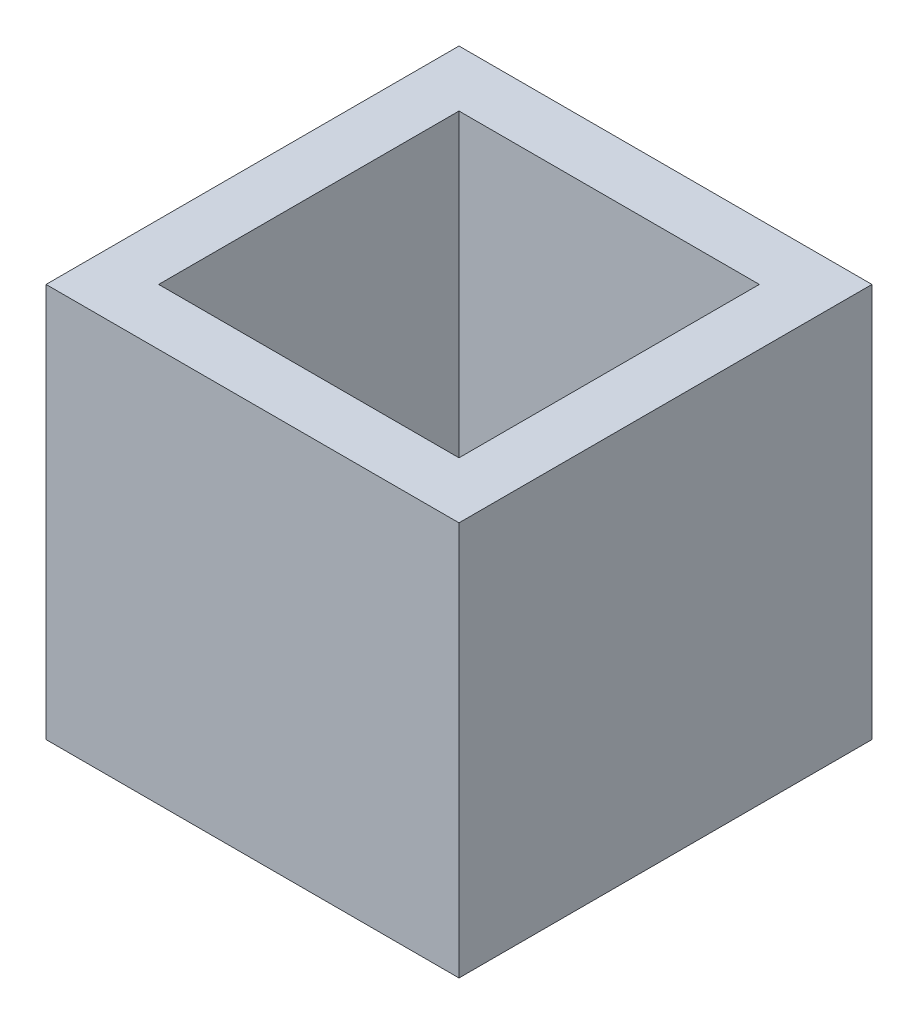
from build123d import *

# Parameters (mm, degrees)
SKETCH1_W           = 12
SKETCH1_H           = 12
BOSS_EXTRUDE1_DEPTH = 11
SHELL1_T            = -2
SKETCH3_R           = 0.625
CUT_EXTRUDE1_DEPTH  = 10
SKETCH4_W           = 12
SKETCH4_H           = 12
SKETCH4_W_2         = 11
SKETCH4_H_2         = 11
CUT_EXTRUDE2_DEPTH  = 12
SKETCH5_W           = 11
SKETCH5_H           = 11
CUT_EXTRUDE3_DEPTH  = 0.5


with BuildPart() as part:
    # Sketch1 → Boss-Extrude1 (new body)
    with BuildSketch(Plane(origin=(0, 0, 0), x_dir=(1, 0, 0), z_dir=(0, 1, 0))):
        with Locations((6, 6)):
            Rectangle(SKETCH1_W, SKETCH1_H)
    extrude(amount=BOSS_EXTRUDE1_DEPTH)

    # Shell1
    shell1_openings = [part.faces().sort_by_distance(p)[0] for p in [
        (6, 11, -6),
    ]]
    offset(amount=SHELL1_T, openings=shell1_openings, kind=Kind.INTERSECTION)

    # Sketch3 → Cut-Extrude1 (cut)
    with BuildSketch(Plane.XZ):
        with Locations((6, -4.73)):
            Circle(SKETCH3_R)
        with Locations((6, -7.27)):
            Circle(SKETCH3_R)
    extrude(amount=-CUT_EXTRUDE1_DEPTH, mode=Mode.SUBTRACT)

    # Sketch4 → Cut-Extrude2 (cut, through all)
    with BuildSketch(Plane(origin=(0, 11, 0), x_dir=(1, 0, 0), z_dir=(0, 1, 0))):
        with Locations((6, 6)):
            Rectangle(SKETCH4_W, SKETCH4_H)
        with Locations((6, 6)):
            Rectangle(SKETCH4_W_2, SKETCH4_H_2, mode=Mode.SUBTRACT)
    extrude(amount=-CUT_EXTRUDE2_DEPTH, mode=Mode.SUBTRACT)

    # Sketch5 → Cut-Extrude3 (cut)
    with BuildSketch(Plane.XZ):
        with Locations((6, -6)):
            Rectangle(SKETCH5_W, SKETCH5_H)
    extrude(amount=-CUT_EXTRUDE3_DEPTH, mode=Mode.SUBTRACT)


solid = part.part
